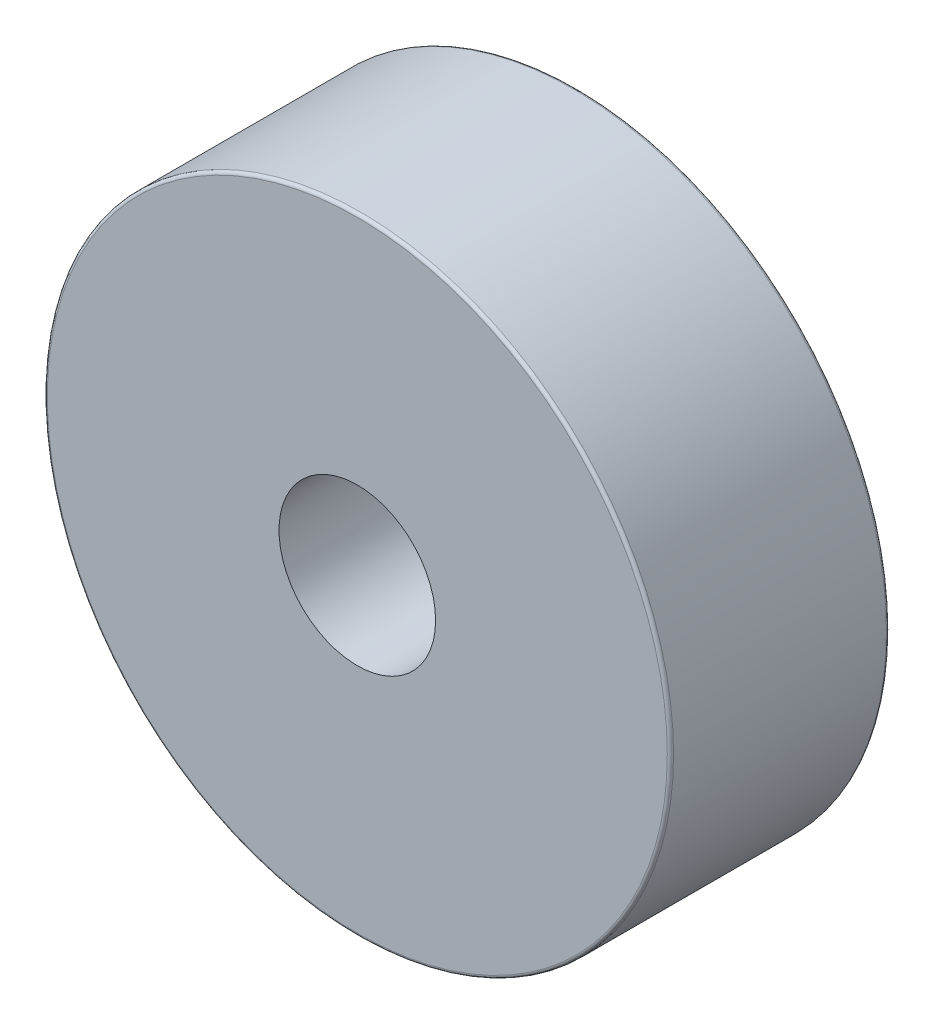
from build123d import *

# Parameters (mm, degrees)
SKETCH_1_R      = 10
SKETCH_1_R_2    = 2.5
EXTRUDE_1_DEPTH = 7
FILLET_1_R      = 0.1


with BuildPart() as part:
    # 草图1 → 凸台-拉伸1 (new body)
    with BuildSketch(Plane.XY):
        Circle(SKETCH_1_R)
        Circle(SKETCH_1_R_2, mode=Mode.SUBTRACT)
    extrude(amount=EXTRUDE_1_DEPTH)

    # 圆角1
    fillet_1_edges = [part.edges().sort_by_distance(p)[0] for p in [
        (-10, 0, 0),
        (-10, 0, 7),
    ]]
    fillet(fillet_1_edges, radius=FILLET_1_R)


solid = part.part
